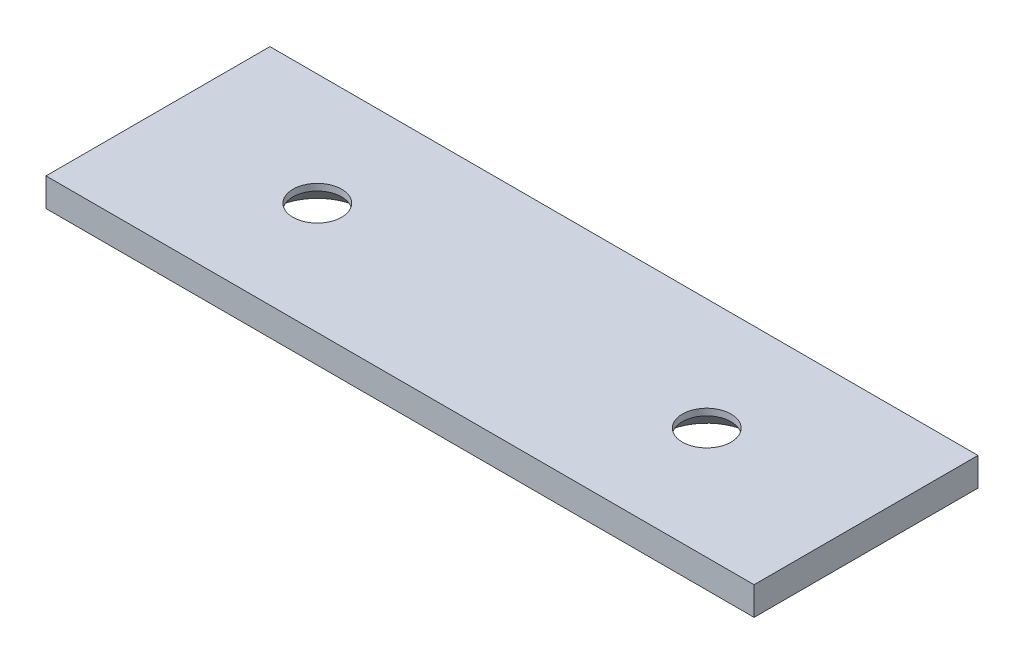
from build123d import *

# Parameters (mm, degrees)
SKETCH1_W                                      = 80
SKETCH1_H                                      = 25.3
BOSS_EXTRUDE1_DEPTH                            = 3.2
CSK_FOR_M5_FLAT_HEAD_MACHINE_SCREW1_AT_2_COUNT = 2
CSK_FOR_M5_FLAT_HEAD_MACHINE_SCREW1_AT_2_PITCH = 44


with BuildPart() as part:
    # Sketch1 → Boss-Extrude1 (new body)
    with BuildSketch(Plane(origin=(0, 0, 0), x_dir=(1, 0, 0), z_dir=(0, 1, 0))):
        with Locations((40, -12.65)):
            Rectangle(SKETCH1_W, SKETCH1_H)
    extrude(amount=BOSS_EXTRUDE1_DEPTH)

    # Sketch3 → CSK for M5 Flat Head Machine Screw1 (revolve, cut)
    with BuildSketch(Plane(origin=(62, 0, 12.65), x_dir=(0, 0, -1), z_dir=(1, 0, 0))):
        Polygon((0, 0), (0, 3.2), (2.75, 3.2), (2.75, 2.45), (5.2, 0), align=None)
    csk_for_m5_flat_head_machine_screw1 = revolve(axis=Axis((62, -6.35, 12.65), (0, 1, 0)), mode=Mode.SUBTRACT)

    # CSK for M5 Flat Head Machine Screw1 at 2: CSK for M5 Flat Head Machine Screw1 ×2
    with Locations(*[(-i * CSK_FOR_M5_FLAT_HEAD_MACHINE_SCREW1_AT_2_PITCH, 0, 0) for i in range(1, CSK_FOR_M5_FLAT_HEAD_MACHINE_SCREW1_AT_2_COUNT)]):
        add(csk_for_m5_flat_head_machine_screw1, mode=Mode.SUBTRACT)


solid = part.part
